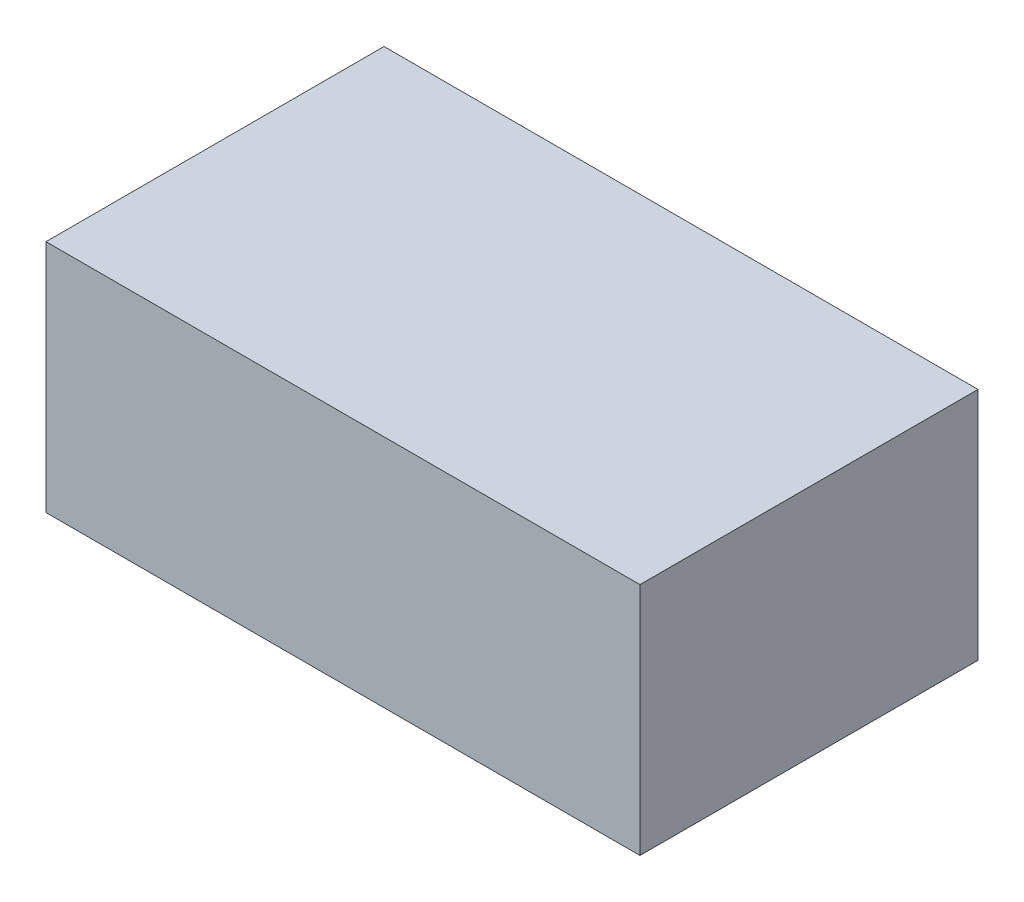
from build123d import *

# Parameters (mm, degrees)
SKETCH1_W           = 55.7
SKETCH1_H           = 31.7
BOSS_EXTRUDE1_DEPTH = 22
SKETCH3_W           = 51.7
SKETCH3_H           = 27.7
CUT_EXTRUDE2_DEPTH  = 20


with BuildPart() as part:
    # Sketch1 → Boss-Extrude1 (new body)
    with BuildSketch(Plane(origin=(0, 0, 0), x_dir=(1, 0, 0), z_dir=(0, 1, 0))):
        with Locations((27.85, 15.85)):
            Rectangle(SKETCH1_W, SKETCH1_H)
    extrude(amount=BOSS_EXTRUDE1_DEPTH)

    # Sketch3 → Cut-Extrude2 (cut)
    with BuildSketch(Plane.XZ):
        with Locations((27.85, -15.85)):
            Rectangle(SKETCH3_W, SKETCH3_H)
    extrude(amount=-CUT_EXTRUDE2_DEPTH, mode=Mode.SUBTRACT)


solid = part.part
